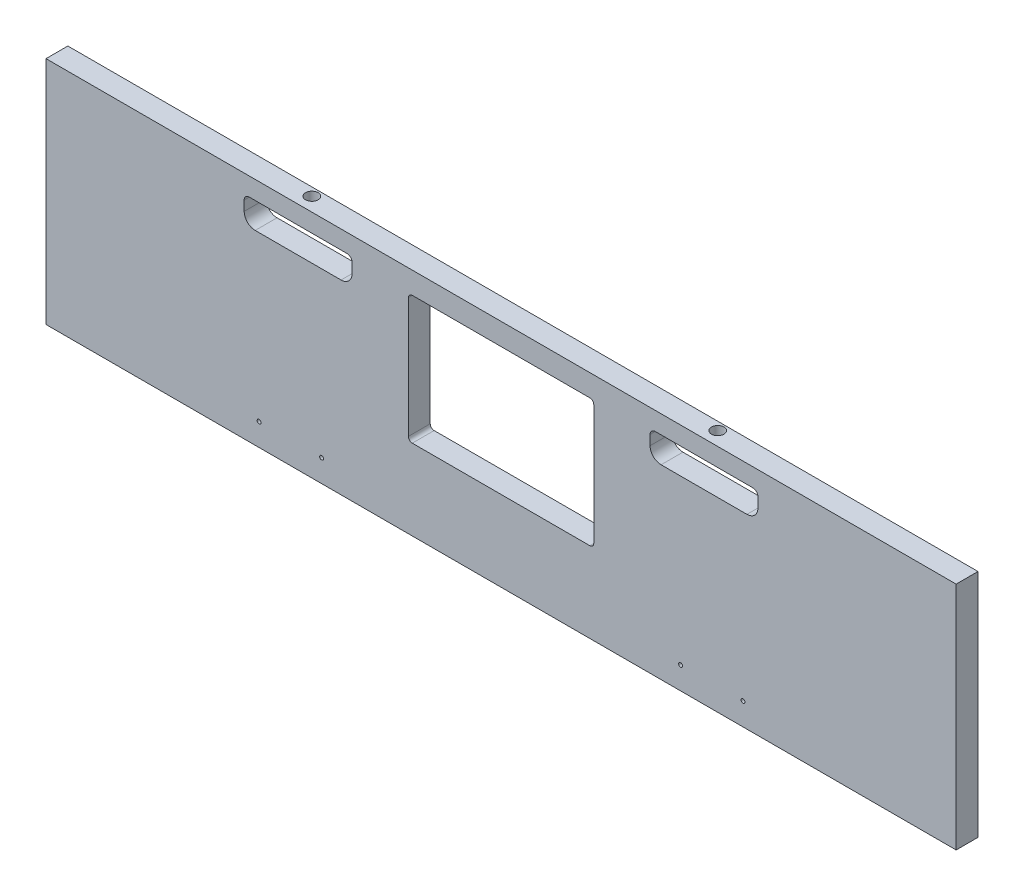
from build123d import *

# Parameters (mm, degrees)
HEADBOTTOMOUTLINE_W               = 740.41
HEADBOTTOMOUTLINE_H               = 187.325
HEADBOTTOMOUTLINE_THICKNESS_DEPTH = 17.78
SKETCH3_R                         = 1.5875
CUT_EXTRUDE1_DEPTH                = 17.78
SKETCH4_R                         = 5.08
CUT_EXTRUDE2_DEPTH                = 14.859


with BuildPart() as part:
    # HeadBottomOutline → HeadBottomOutline_Thickness (new body)
    with BuildSketch(Plane.XY):
        with Locations((-233.045, -5408.6125)):
            Rectangle(HEADBOTTOMOUTLINE_W, HEADBOTTOMOUTLINE_H)
    extrude(amount=-HEADBOTTOMOUTLINE_THICKNESS_DEPTH)

    # Sketch3 → Cut-Extrude1 (cut)
    with BuildSketch(Plane.XY):
        with Locations((-429.895, -5484.0124)):
            Circle(SKETCH3_R)
        with Locations((-379.095, -5484.0124)):
            Circle(SKETCH3_R)
        with Locations((-86.995, -5484.0124)):
            Circle(SKETCH3_R)
        with Locations((-36.195, -5484.0124)):
            Circle(SKETCH3_R)
        with BuildLine():
            Line((-308.45125, -5335.905), (-308.45125, -5433.695))
            ThreePointArc((-308.45125, -5433.695), (-307.52131403, -5435.94006403), (-305.27625, -5436.87))
            Line((-305.27625, -5436.87), (-160.81375, -5436.87))
            ThreePointArc((-160.81375, -5436.87), (-158.56868597, -5435.94006403), (-157.63875, -5433.695))
            Line((-157.63875, -5433.695), (-157.63875, -5335.905))
            ThreePointArc((-157.63875, -5335.905), (-158.56868597, -5333.65993597), (-160.81375, -5332.73))
            Line((-160.81375, -5332.73), (-305.27625, -5332.73))
            ThreePointArc((-305.27625, -5332.73), (-307.52131403, -5333.65993597), (-308.45125, -5335.905))
        make_face()
        with BuildLine():
            Line((-354.2665, -5334), (-354.2665, -5341.9375))
            ThreePointArc((-354.2665, -5341.9375), (-356.888919435, -5348.268580565), (-363.22, -5350.891))
            Line((-363.22, -5350.891), (-433.07, -5350.891))
            ThreePointArc((-433.07, -5350.891), (-439.401080565, -5348.268580565), (-442.0235, -5341.9375))
            Line((-442.0235, -5341.9375), (-442.0235, -5334))
            ThreePointArc((-442.0235, -5334), (-440.79598452, -5331.03651548), (-437.8325, -5329.809))
            Line((-437.8325, -5329.809), (-358.4575, -5329.809))
            ThreePointArc((-358.4575, -5329.809), (-355.49401548, -5331.03651548), (-354.2665, -5334))
        make_face()
        with BuildLine():
            Line((-102.87, -5350.891), (-33.02, -5350.891))
            ThreePointArc((-33.02, -5350.891), (-26.688919435, -5348.268580565), (-24.0665, -5341.9375))
            Line((-24.0665, -5341.9375), (-24.0665, -5334))
            ThreePointArc((-24.0665, -5334), (-25.29401548, -5331.03651548), (-28.2575, -5329.809))
            Line((-28.2575, -5329.809), (-107.6325, -5329.809))
            ThreePointArc((-107.6325, -5329.809), (-110.59598452, -5331.03651548), (-111.8235, -5334))
            Line((-111.8235, -5334), (-111.8235, -5341.9375))
            ThreePointArc((-111.8235, -5341.9375), (-109.201080565, -5348.268580565), (-102.87, -5350.891))
        make_face()
    extrude(amount=-CUT_EXTRUDE1_DEPTH, mode=Mode.SUBTRACT)

    # Sketch4 → Cut-Extrude2 (cut)
    with BuildSketch(Plane(origin=(0, -5314.95, 0), x_dir=(1, 0, 0), z_dir=(0, 1, 0))):
        with Locations((-67.9699936, 11.187303)):
            Circle(SKETCH4_R)
        with Locations((-398.1699936, 11.187303)):
            Circle(SKETCH4_R)
    extrude(amount=-CUT_EXTRUDE2_DEPTH, mode=Mode.SUBTRACT)


solid = part.part
